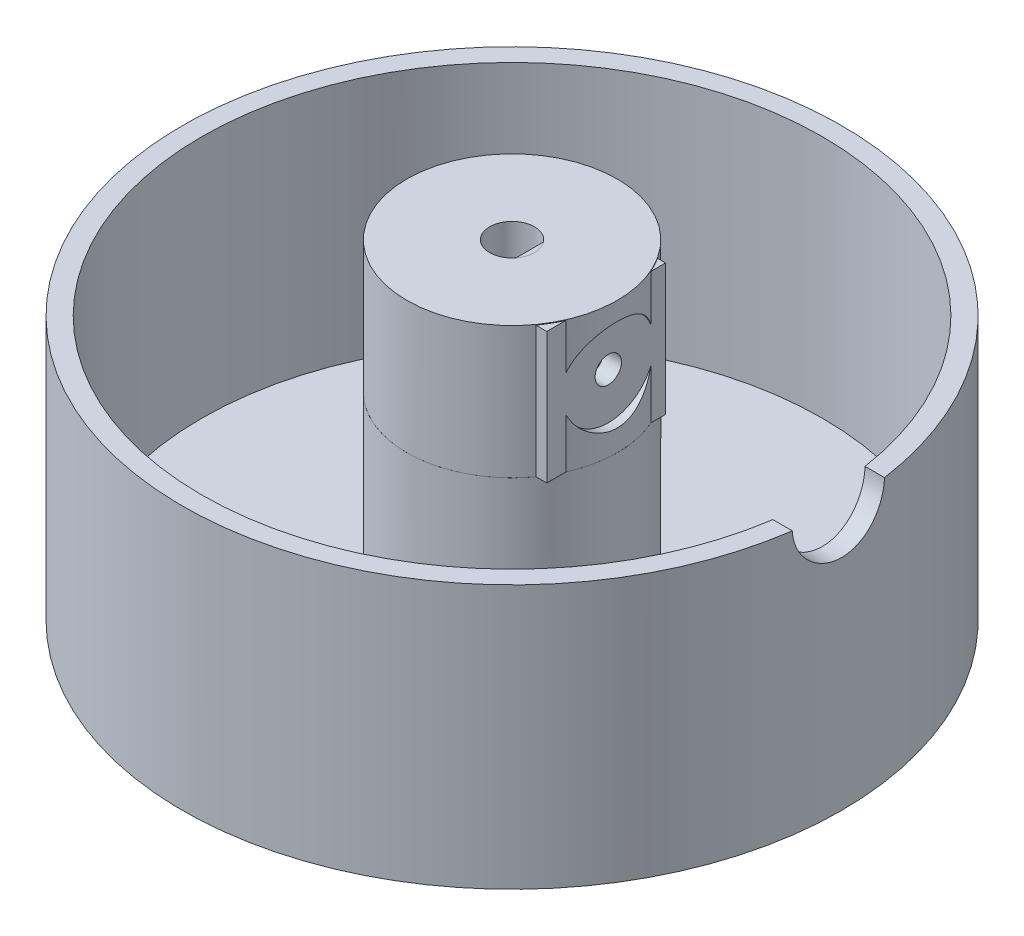
from build123d import *

# Parameters (mm, degrees)
SKETCH1_R               = 15.958
BOSS_EXTRUDE1_DEPTH     = 20
SKETCH2_R               = 3.4
CUT_EXTRUDE1_DEPTH      = 13.55
SKETCH5_W               = 1.550685087
SKETCH5_H               = 7.184215806
BOSS_EXTRUDE2_DEPTH     = 13.55
SKETCH7_W               = 18.003976239
SKETCH7_H               = 19.909960041
BOSS_EXTRUDE3_DEPTH     = 12
SKETCH6_R               = 2
CUT_EXTRUDE2_DEPTH      = 1
CUT_EXTRUDE2_DEPTH_BACK = 13.55
NUTOPENING_DEPTH        = 30
SKETCH10_R              = 50
BOSS_EXTRUDE4_DEPTH     = 30
SKETCH12_R              = 47.082764373
SKETCH12_R_2            = 15.95790089
CUT_EXTRUDE5_DEPTH      = 27
SKETCH13_R              = 50
SKETCH13_R_2            = 47.082764373
BOSS_EXTRUDE5_DEPTH     = 10
CUT_EXTRUDE6_DEPTH      = 6.933086
SKETCH16_R              = 7
CUT_EXTRUDE7_DEPTH      = 40


with BuildPart() as part:
    # Sketch1 → Boss-Extrude1 (new body)
    with BuildSketch(Plane(origin=(0, 0, 0), x_dir=(1, 0, 0), z_dir=(0, 1, 0))):
        Circle(SKETCH1_R)
    extrude(amount=BOSS_EXTRUDE1_DEPTH)

    # Sketch2 → Cut-Extrude1 (cut)
    with BuildSketch(Plane(origin=(0, 20, 0), x_dir=(1, 0, 0), z_dir=(0, 1, 0))):
        Circle(SKETCH2_R)
    extrude(amount=-CUT_EXTRUDE1_DEPTH, mode=Mode.SUBTRACT)

    # Sketch5 → Boss-Extrude2 (add)
    with BuildSketch(Plane(origin=(0, 18.26, 0), x_dir=(1, 0, 0), z_dir=(0, 1, 0))):
        with Locations((3.375342544, 0.020519704)):
            Rectangle(SKETCH5_W, SKETCH5_H)
    extrude(amount=-BOSS_EXTRUDE2_DEPTH)

    # Sketch7 → Boss-Extrude3 (add)
    with BuildSketch(Plane.ZY.offset(-2.6)):
        with Locations((0.33027221, 9.954980021)):
            Rectangle(SKETCH7_W, SKETCH7_H)
    extrude(amount=-BOSS_EXTRUDE3_DEPTH)

    # Sketch6 → Cut-Extrude2 (cut, two sides)
    with BuildSketch(Plane.ZY.offset(-2.6)) as cut_extrude2_sk:
        with Locations((0, 10.236925537)):
            Circle(SKETCH6_R)
    extrude(amount=CUT_EXTRUDE2_DEPTH, mode=Mode.SUBTRACT)
    extrude(cut_extrude2_sk.sketch, amount=-CUT_EXTRUDE2_DEPTH_BACK, mode=Mode.SUBTRACT)

    # Sketch9 → NutOpening (cut)
    with BuildSketch(Plane.XY):
        Polygon((11.876516377, 10.236925537), (11.876516377, 5.861925537), (4.943430227, 5.861925537), (4.943430227, 10.236925537), (4.943430227, 14.614332445), (11.876516377, 14.614332445), align=None)
    extrude(amount=-NUTOPENING_DEPTH, mode=Mode.SUBTRACT)

    # Sketch10 → Boss-Extrude4 (add)
    with BuildSketch(Plane.XZ):
        Circle(SKETCH10_R)
    extrude(amount=BOSS_EXTRUDE4_DEPTH)

    # Sketch12 → Cut-Extrude5 (cut)
    with BuildSketch(Plane(origin=(0, 0, 0), x_dir=(1, 0, 0), z_dir=(0, 1, 0))):
        Circle(SKETCH12_R)
        Circle(SKETCH12_R_2, mode=Mode.SUBTRACT)
    extrude(amount=-CUT_EXTRUDE5_DEPTH, mode=Mode.SUBTRACT)

    # Sketch13 → Boss-Extrude5 (add)
    with BuildSketch(Plane(origin=(0, 0, 0), x_dir=(1, 0, 0), z_dir=(0, 1, 0))):
        Circle(SKETCH13_R)
        Circle(SKETCH13_R_2, mode=Mode.SUBTRACT)
    extrude(amount=BOSS_EXTRUDE5_DEPTH)

    # Sketch14 → Cut-Extrude6 (cut)
    with BuildSketch(Plane.ZY.offset(-11.876516377)):
        Polygon((-5.054124256, 10.236925537), (-2.527062128, 5.859925537), (2.527062128, 5.859925537), (5.054124256, 10.236925537), (2.527062128, 14.613925537), (-2.527062128, 14.613925537), align=None)
    extrude(amount=CUT_EXTRUDE6_DEPTH, mode=Mode.SUBTRACT)

    # Sketch16 → Cut-Extrude7 (cut)
    with BuildSketch(Plane(origin=(14.6, 0, 0), x_dir=(0, 0, -1), z_dir=(1, 0, 0))):
        with Locations((0, 10.236925537)):
            Circle(SKETCH16_R)
    extrude(amount=CUT_EXTRUDE7_DEPTH, mode=Mode.SUBTRACT)


solid = part.part
